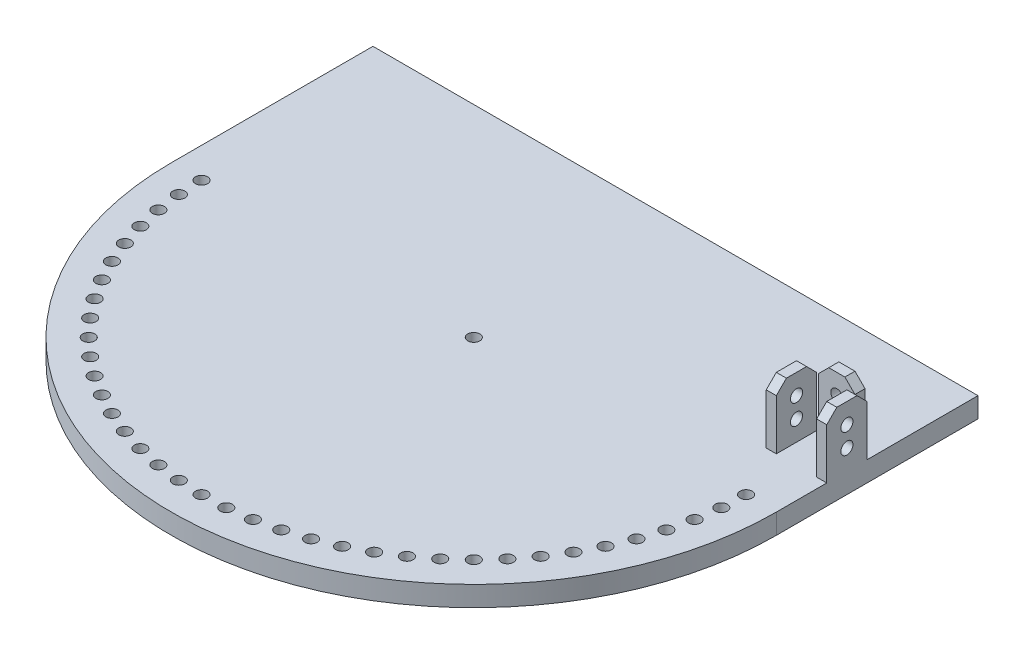
from build123d import *

# Parameters (mm, degrees)
SKETCH1_R           = 3
BOSS_EXTRUDE1_DEPTH = 10
BOSS_EXTRUDE2_START = -300
SKETCH2_R           = 3
BOSS_EXTRUDE2_DEPTH = 5
BOSS_EXTRUDE3_START = -270
SKETCH2_2_R         = 3
BOSS_EXTRUDE3_DEPTH = 5
SKETCH3_W           = 18
SKETCH3_H           = 5
BOSS_EXTRUDE5_DEPTH = 30
SKETCH4_R           = 3
CUT_EXTRUDE1_DEPTH  = 30


with BuildPart() as part:
    # Sketch1 → Boss-Extrude1 (new body)
    with BuildSketch(Plane(origin=(0, 0, 0), x_dir=(1, 0, 0), z_dir=(0, 1, 0))):
        with BuildLine():
            Line((-150, 100), (150, 100))
            Line((150, 100), (150, 0))
            ThreePointArc((150, 0), (0, -150), (-150, 0))
            Line((-150, 0), (-150, 100))
        make_face()
        Circle(SKETCH1_R, mode=Mode.SUBTRACT)
        with Locations((135, 0)):
            Circle(SKETCH1_R, mode=Mode.SUBTRACT)
        with Locations((134.486284242, -11.766025271)):
            Circle(SKETCH1_R, mode=Mode.SUBTRACT)
        with Locations((132.949046657, -23.442503985)):
            Circle(SKETCH1_R, mode=Mode.SUBTRACT)
        with Locations((130.399986549, -34.940571089)):
            Circle(SKETCH1_R, mode=Mode.SUBTRACT)
        with Locations((126.858503806, -46.172719349)):
            Circle(SKETCH1_R, mode=Mode.SUBTRACT)
        with Locations((122.35155125, -57.053465335)):
            Circle(SKETCH1_R, mode=Mode.SUBTRACT)
        with Locations((116.913429511, -67.5)):
            Circle(SKETCH1_R, mode=Mode.SUBTRACT)
        with Locations((110.585525979, -77.432818907)):
            Circle(SKETCH1_R, mode=Mode.SUBTRACT)
        with Locations((103.415999821, -86.776327308)):
            Circle(SKETCH1_R, mode=Mode.SUBTRACT)
        with Locations((95.45941546, -95.45941546)):
            Circle(SKETCH1_R, mode=Mode.SUBTRACT)
        with Locations((86.776327308, -103.415999821)):
            Circle(SKETCH1_R, mode=Mode.SUBTRACT)
        with Locations((77.432818907, -110.585525979)):
            Circle(SKETCH1_R, mode=Mode.SUBTRACT)
        with Locations((67.5, -116.913429511)):
            Circle(SKETCH1_R, mode=Mode.SUBTRACT)
        with Locations((57.053465335, -122.35155125)):
            Circle(SKETCH1_R, mode=Mode.SUBTRACT)
        with Locations((46.172719349, -126.858503806)):
            Circle(SKETCH1_R, mode=Mode.SUBTRACT)
        with Locations((34.940571089, -130.399986549)):
            Circle(SKETCH1_R, mode=Mode.SUBTRACT)
        with Locations((23.442503985, -132.949046657)):
            Circle(SKETCH1_R, mode=Mode.SUBTRACT)
        with Locations((11.766025271, -134.486284242)):
            Circle(SKETCH1_R, mode=Mode.SUBTRACT)
        with Locations((0, -135)):
            Circle(SKETCH1_R, mode=Mode.SUBTRACT)
        with Locations((-11.766025271, -134.486284242)):
            Circle(SKETCH1_R, mode=Mode.SUBTRACT)
        with Locations((-23.442503985, -132.949046657)):
            Circle(SKETCH1_R, mode=Mode.SUBTRACT)
        with Locations((-34.940571089, -130.399986549)):
            Circle(SKETCH1_R, mode=Mode.SUBTRACT)
        with Locations((-46.172719349, -126.858503806)):
            Circle(SKETCH1_R, mode=Mode.SUBTRACT)
        with Locations((-57.053465335, -122.35155125)):
            Circle(SKETCH1_R, mode=Mode.SUBTRACT)
        with Locations((-67.5, -116.913429511)):
            Circle(SKETCH1_R, mode=Mode.SUBTRACT)
        with Locations((-77.432818907, -110.585525979)):
            Circle(SKETCH1_R, mode=Mode.SUBTRACT)
        with Locations((-86.776327308, -103.415999821)):
            Circle(SKETCH1_R, mode=Mode.SUBTRACT)
        with Locations((-95.45941546, -95.45941546)):
            Circle(SKETCH1_R, mode=Mode.SUBTRACT)
        with Locations((-103.415999821, -86.776327308)):
            Circle(SKETCH1_R, mode=Mode.SUBTRACT)
        with Locations((-110.585525979, -77.432818907)):
            Circle(SKETCH1_R, mode=Mode.SUBTRACT)
        with Locations((-116.913429511, -67.5)):
            Circle(SKETCH1_R, mode=Mode.SUBTRACT)
        with Locations((-122.35155125, -57.053465335)):
            Circle(SKETCH1_R, mode=Mode.SUBTRACT)
        with Locations((-126.858503806, -46.172719349)):
            Circle(SKETCH1_R, mode=Mode.SUBTRACT)
        with Locations((-130.399986549, -34.940571089)):
            Circle(SKETCH1_R, mode=Mode.SUBTRACT)
        with Locations((-132.949046657, -23.442503985)):
            Circle(SKETCH1_R, mode=Mode.SUBTRACT)
        with Locations((-134.486284242, -11.766025271)):
            Circle(SKETCH1_R, mode=Mode.SUBTRACT)
        with Locations((-135, 0)):
            Circle(SKETCH1_R, mode=Mode.SUBTRACT)
    extrude(amount=BOSS_EXTRUDE1_DEPTH)

    # Sketch2 → Boss-Extrude2 (add)
    with BuildSketch(Plane.ZY.offset(150).offset(BOSS_EXTRUDE2_START)):
        Polygon((-25, 10), (-25, 35), (-30, 40), (-40, 40), (-45, 35), (-45, 10), align=None)
        with Locations((-35, 30)):
            Circle(SKETCH2_R, mode=Mode.SUBTRACT)
        with Locations((-35, 20)):
            Circle(SKETCH2_R, mode=Mode.SUBTRACT)
    extrude(amount=BOSS_EXTRUDE2_DEPTH)

    # Sketch2_2 → Boss-Extrude3 (add)
    with BuildSketch(Plane.ZY.offset(150).offset(BOSS_EXTRUDE3_START)):
        Polygon((-25, 10), (-25, 35), (-30, 40), (-40, 40), (-45, 35), (-45, 10), align=None)
        with Locations((-35, 30)):
            Circle(SKETCH2_2_R, mode=Mode.SUBTRACT)
        with Locations((-35, 20)):
            Circle(SKETCH2_2_R, mode=Mode.SUBTRACT)
    extrude(amount=-BOSS_EXTRUDE3_DEPTH)

    # Sketch3 → Boss-Extrude5 (add)
    with BuildSketch(Plane(origin=(0, 10, 0), x_dir=(1, 0, 0), z_dir=(0, 1, 0))):
        with Locations((135, 47.5)):
            Rectangle(SKETCH3_W, SKETCH3_H)
    extrude(amount=BOSS_EXTRUDE5_DEPTH)

    # Sketch4 → Cut-Extrude1 (cut)
    with BuildSketch(Plane.XY.offset(-45)):
        with Locations((135, 20)):
            Circle(SKETCH4_R)
        with Locations((135, 30)):
            Circle(SKETCH4_R)
        Polygon((126, 35), (131, 40), (126, 40), align=None)
        Polygon((139, 40), (144, 35), (144, 40), align=None)
    extrude(amount=-CUT_EXTRUDE1_DEPTH, mode=Mode.SUBTRACT)


solid = part.part
